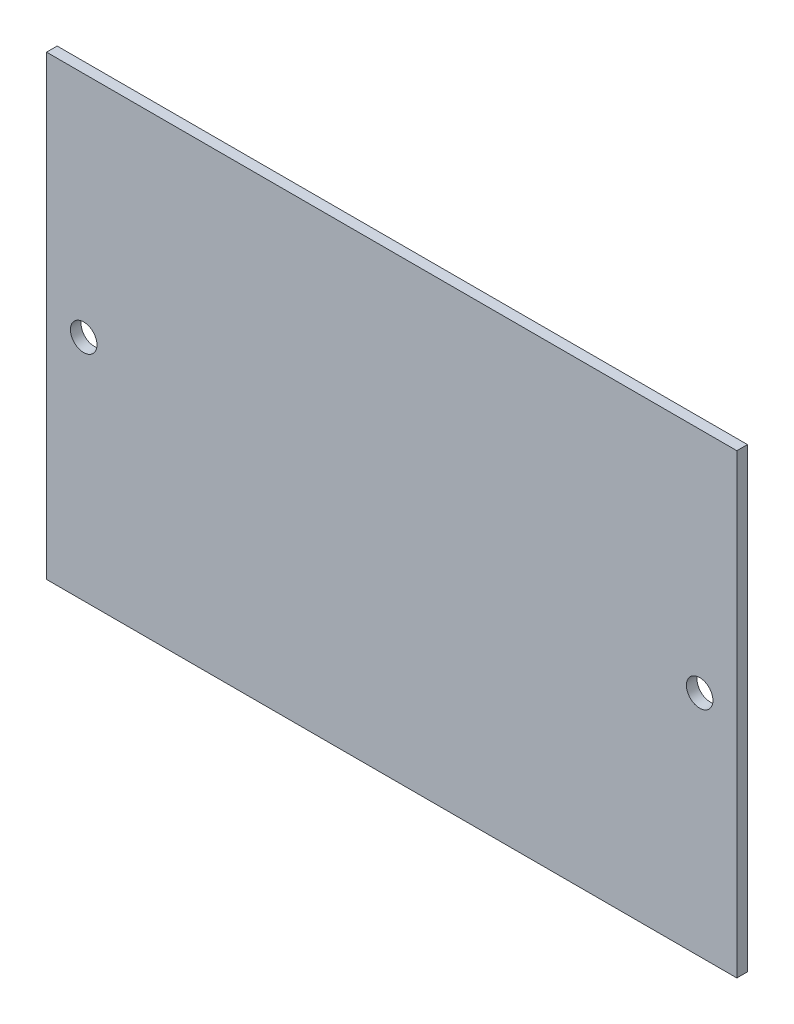
from build123d import *

# Parameters (mm, degrees)
SKETCH1_W           = 130
SKETCH1_H           = 86
SKETCH1_R           = 2.5
BOSS_EXTRUDE1_DEPTH = 2


with BuildPart() as part:
    # Sketch1 → Boss-Extrude1 (new body)
    with BuildSketch(Plane.XY):
        Rectangle(SKETCH1_W, SKETCH1_H)
        with Locations((-58, 0)):
            Circle(SKETCH1_R, mode=Mode.SUBTRACT)
        with Locations((58, 0)):
            Circle(SKETCH1_R, mode=Mode.SUBTRACT)
    extrude(amount=BOSS_EXTRUDE1_DEPTH)


solid = part.part
